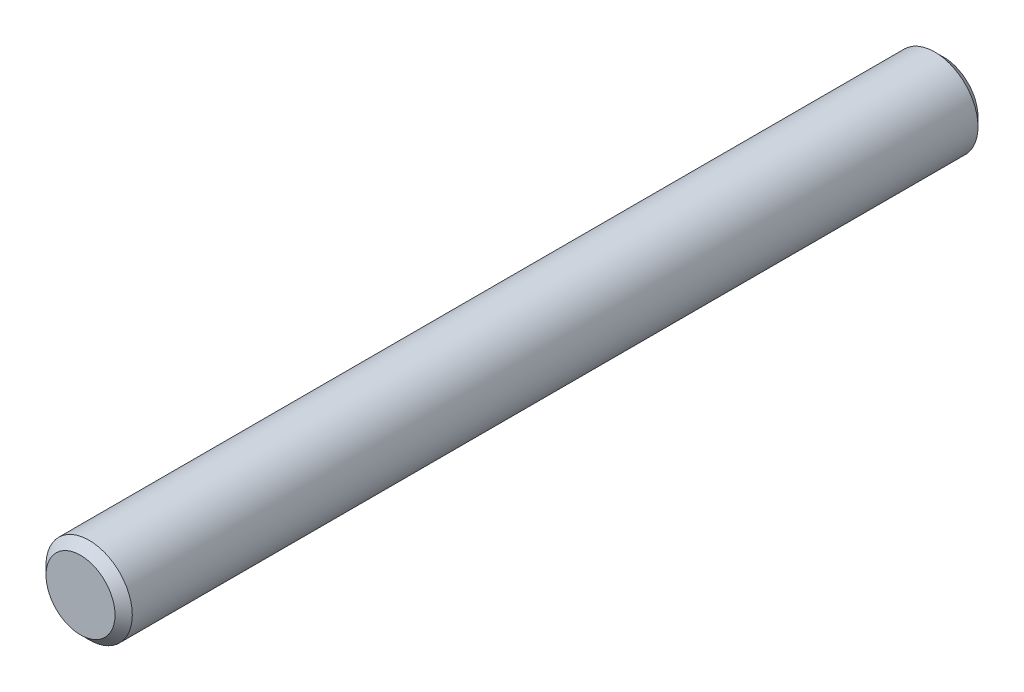
from build123d import *

# Parameters (mm, degrees)
SKETCH_1_R      = 1
EXTRUDE_1_DEPTH = 10
CHAMFER_1_SIZE  = 0.2


with BuildPart() as part:
    # 草图1 → 凸台-拉伸1 (new body, symmetric)
    with BuildSketch(Plane.XY):
        Circle(SKETCH_1_R)
    extrude(amount=EXTRUDE_1_DEPTH, both=True)

    # 倒角1
    chamfer_1_edges = [part.edges().sort_by_distance(p)[0] for p in [
        (-1, 0, -10),
        (-1, 0, 10),
    ]]
    chamfer(chamfer_1_edges, length=CHAMFER_1_SIZE)


solid = part.part
